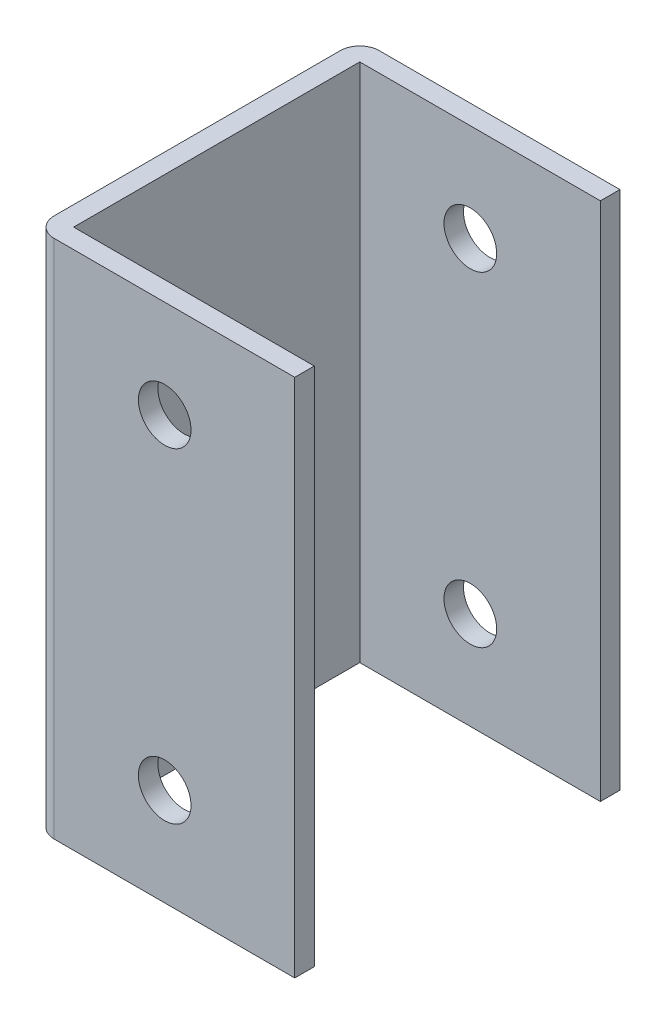
from build123d import *

# Parameters (mm, degrees)
SKETCH_1_W          = 74
SKETCH_1_H          = 44
EXTRUDE_1_DEPTH     = 80
SKETCH_2_W          = 41.146480438
SKETCH_2_H          = 58.393385187
CUT_EXTRUDE_1_DEPTH = 81
SKETCH_3_R          = 4.05
CUT_EXTRUDE_2_DEPTH = 51


with BuildPart() as part:
    # Эскиз1 → Вытянуть-Тонкостенный1 (new body)
    with BuildSketch(Plane(origin=(0, 0, 0), x_dir=(1, 0, 0), z_dir=(0, 1, 0))):
        with BuildLine():
            Line((40, 22), (40, -22))
            ThreePointArc((40, -22), (39.121320344, -24.121320344), (37, -25))
            Line((37, -25), (-37, -25))
            ThreePointArc((-37, -25), (-39.121320344, -24.121320344), (-40, -22))
            Line((-40, -22), (-40, 22))
            ThreePointArc((-40, 22), (-39.121320344, 24.121320344), (-37, 25))
            Line((-37, 25), (37, 25))
            ThreePointArc((37, 25), (39.121320344, 24.121320344), (40, 22))
        make_face()
        Rectangle(SKETCH_1_W, SKETCH_1_H, mode=Mode.SUBTRACT)
    extrude(amount=EXTRUDE_1_DEPTH)

    # Эскиз2 → Вырез-Вытянуть1 (cut, through all)
    with BuildSketch(Plane(origin=(0, 80, 0), x_dir=(1, 0, 0), z_dir=(0, 1, 0))):
        with Locations((20.573240219, 1.776081122)):
            Rectangle(SKETCH_2_W, SKETCH_2_H)
    extrude(amount=-CUT_EXTRUDE_1_DEPTH, mode=Mode.SUBTRACT)

    # Эскиз3 → Вырез-Вытянуть2 (cut, through all)
    with BuildSketch(Plane(origin=(0, 0, -25), x_dir=(-1, 0, 0), z_dir=(0, 0, -1))):
        with Locations((20, 115)):
            Circle(SKETCH_3_R)
        with Locations((20, 15)):
            Circle(SKETCH_3_R)
        with Locations((20, 65)):
            Circle(SKETCH_3_R)
    extrude(amount=-CUT_EXTRUDE_2_DEPTH, mode=Mode.SUBTRACT)


solid = part.part
